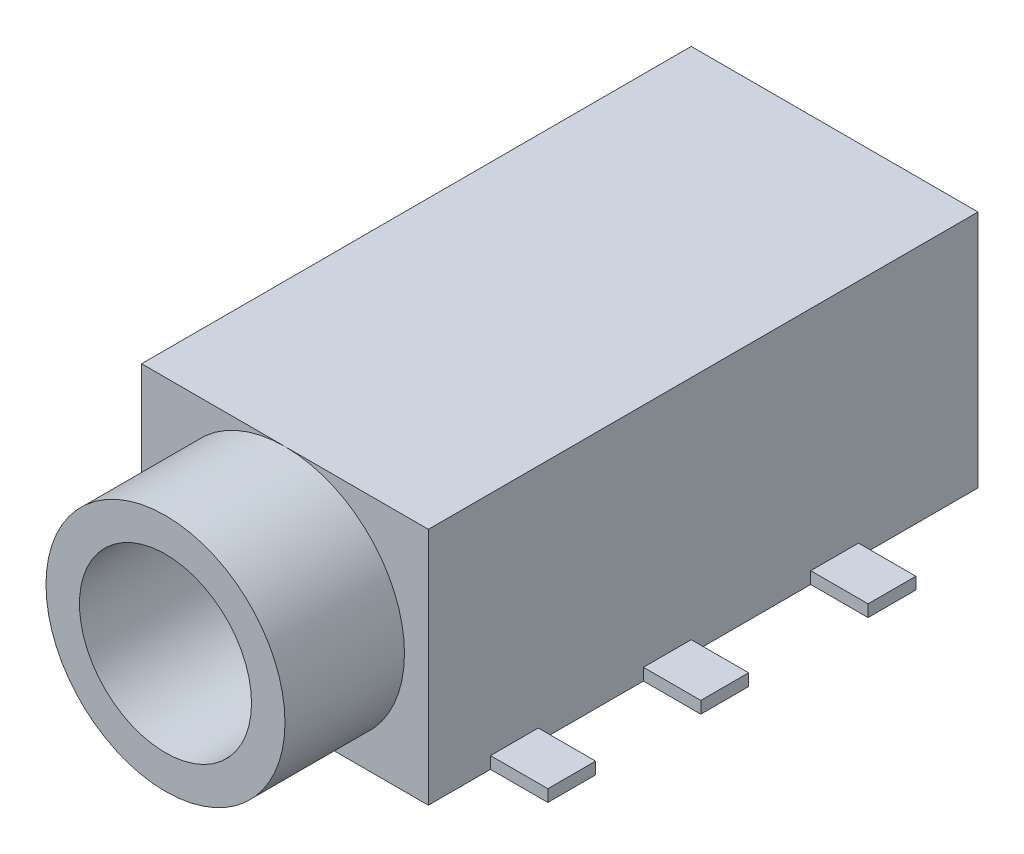
from build123d import *

# Parameters (mm, degrees)
SKETCH_1_W          = 6
SKETCH_1_H          = 11.5
EXTRUDE_1_DEPTH     = 5
SKETCH_2_R          = 2.5
EXTRUDE_2_DEPTH     = 2.5
SKETCH_3_R          = 0.75
EXTRUDE_3_DEPTH     = 0.5
SKETCH_4_W          = 1
SKETCH_4_H          = 0.25
EXTRUDE_4_DEPTH     = 1.2
SKETCH_5_R          = 1.8
CUT_EXTRUDE_1_DEPTH = 15


with BuildPart() as part:
    # 草图1 → 凸台-拉伸1 (new body)
    with BuildSketch(Plane(origin=(0, 0, 0), x_dir=(1, 0, 0), z_dir=(0, 1, 0))):
        with Locations((0, 5.75)):
            Rectangle(SKETCH_1_W, SKETCH_1_H)
    extrude(amount=EXTRUDE_1_DEPTH)

    # 草图2 → 凸台-拉伸2 (add)
    with BuildSketch(Plane.XY):
        with Locations((0, 2.5)):
            Circle(SKETCH_2_R)
    extrude(amount=EXTRUDE_2_DEPTH)

    # 草图3 → 凸台-拉伸3 (add)
    with BuildSketch(Plane.XZ):
        with Locations((0, -2.5)):
            Circle(SKETCH_3_R)
        with Locations((0, -8.5)):
            Circle(SKETCH_3_R)
    extrude(amount=EXTRUDE_3_DEPTH)

    # 草图4 → 凸台-拉伸4 (add)
    with BuildSketch(Plane(origin=(3, 0, 0), x_dir=(0, 0, -1), z_dir=(1, 0, 0))):
        with Locations((1.8, 0.125)):
            Rectangle(SKETCH_4_W, SKETCH_4_H)
        with Locations((5, 0.125)):
            Rectangle(SKETCH_4_W, SKETCH_4_H)
        with Locations((8.5, 0.125)):
            Rectangle(SKETCH_4_W, SKETCH_4_H)
    extrude_4 = extrude(amount=EXTRUDE_4_DEPTH)

    # 镜向1: 凸台-拉伸4 across plane
    add(extrude_4.mirror(Plane(origin=(0, 0, 0), x_dir=(0, 0, 1), z_dir=(1, 0, 0))))

    # 草图5 → 切除-拉伸1 (cut, through all)
    with BuildSketch(Plane.XY.offset(2.5)):
        with Locations((0, 2.5)):
            Circle(SKETCH_5_R)
    extrude(amount=-CUT_EXTRUDE_1_DEPTH, mode=Mode.SUBTRACT)


solid = part.part
